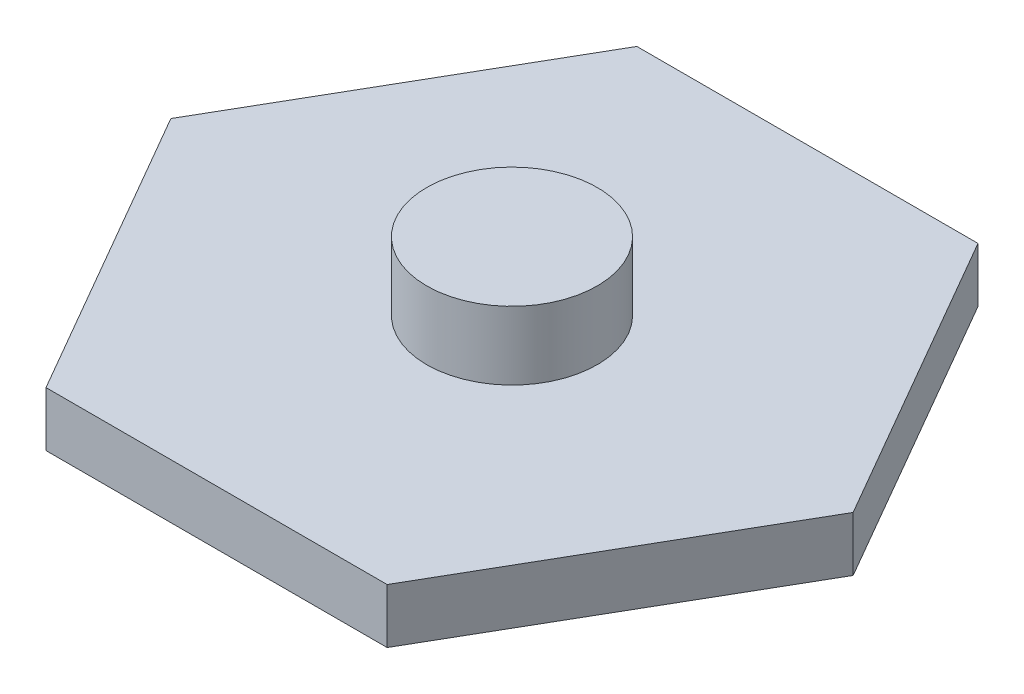
from build123d import *

# Parameters (mm, degrees)
EXTRUDE_1_DEPTH = 1.6
SKETCH_2_R      = 2.5
EXTRUDE_2_DEPTH = 2


with BuildPart() as part:
    # 草图1 → 凸台-拉伸1 (new body)
    with BuildSketch(Plane(origin=(0, 0, 0), x_dir=(1, 0, 0), z_dir=(0, 1, 0))):
        Polygon((10, 0), (5, 8.660254038), (-5, 8.660254038), (-10, 0), (-5, -8.660254038), (5, -8.660254038), align=None)
    extrude(amount=EXTRUDE_1_DEPTH)

    # 草图2 → 凸台-拉伸2 (add)
    with BuildSketch(Plane(origin=(0, 1.6, 0), x_dir=(1, 0, 0), z_dir=(0, 1, 0))):
        Circle(SKETCH_2_R)
    extrude(amount=EXTRUDE_2_DEPTH)


solid = part.part
